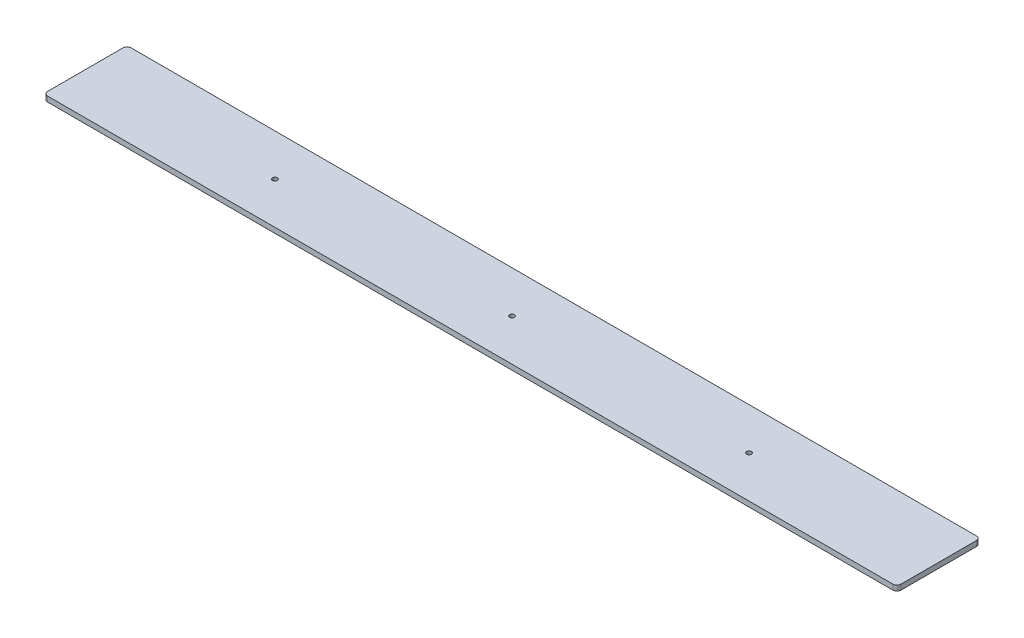
from build123d import *

# Parameters (mm, degrees)
SKETCH1_W             = 519.1125
SKETCH1_H             = 50.8
BOSS_EXTRUDE1_DEPTH   = 3.175
FILLET1_R             = 2.54
F_4_CLEARANCE_HOLE1_D = 2.9464


with BuildPart() as part:
    # Sketch1 → Boss-Extrude1 (new body)
    with BuildSketch(Plane(origin=(0, 0, 0), x_dir=(1, 0, 0), z_dir=(0, 1, 0))):
        Rectangle(SKETCH1_W, SKETCH1_H)
    extrude(amount=BOSS_EXTRUDE1_DEPTH)

    # Fillet1
    fillet1_edges = [part.edges().sort_by_distance(p)[0] for p in [
        (259.55625, 1.5875, 25.4),
        (-259.55625, 1.5875, 25.4),
        (-259.55625, 1.5875, -25.4),
        (259.55625, 1.5875, -25.4),
    ]]
    fillet(fillet1_edges, radius=FILLET1_R)

    # #4 Clearance Hole1 (through all)
    with Locations(Plane(origin=(0, 0, 0), x_dir=(-1, 0, 0), z_dir=(0, -1, 0))):
        with Locations((-144.19199, 0), (0, 0), (144.19961, 0)):
            Hole(F_4_CLEARANCE_HOLE1_D / 2)


solid = part.part
